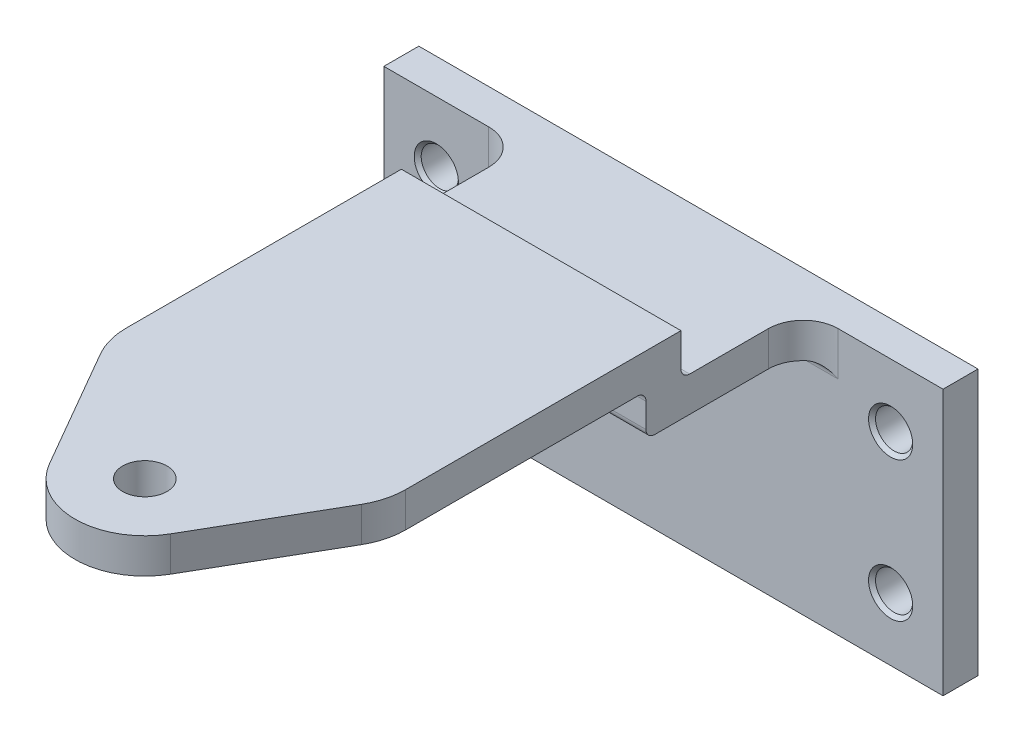
from build123d import *

# Parameters (mm, degrees)
SKETCH1_R                        = 4.03225
BOSS_EXTRUDE1_DEPTH              = 3.175
FILLET1_R                        = 12.7
EXTRUDE_THIN1_DEPTH              = 50.8
SKETCH3_W                        = 6.35
SKETCH3_H                        = 48.26
BOSS_EXTRUDE2_DEPTH              = 25.4
F_1_4_CLEARANCE_HOLE1_AT_2_COUNT = 2
F_1_4_CLEARANCE_HOLE1_AT_2_PITCH = 25.4
FILLET2_R                        = 6.35
FILLET3_R                        = 1.5875


with BuildPart() as part:
    # Sketch1 → Boss-Extrude1 (new, symmetric)
    with BuildSketch(Plane(origin=(0, 0, 0), x_dir=(1, 0, 0), z_dir=(0, 1, 0))):
        with BuildLine():
            Line((-25.4, 50.8), (25.4, 50.8))
            Line((25.4, 50.8), (25.4, 18.594090512))
            Line((25.4, 18.594090512), (10.998522628, -6.35))
            ThreePointArc((10.998522628, -6.35), (0, -12.7), (-10.998522628, -6.35))
            Line((-10.998522628, -6.35), (-25.4, 18.594090512))
            Line((-25.4, 18.594090512), (-25.4, 50.8))
        make_face()
        with Locations(Location((0, 0, 0), (0, 0, 270))):
            Circle(SKETCH1_R, mode=Mode.SUBTRACT)
    extrude(amount=BOSS_EXTRUDE1_DEPTH, both=True)

    # Fillet1
    fillet1_edges = [part.edges().sort_by_distance(p)[0] for p in [
        (25.4, 0, -18.594090512),
        (-25.4, 0, -18.594090512),
    ]]
    fillet(fillet1_edges, radius=FILLET1_R)

    # Sketch2 → Extrude-Thin1 (add)
    with BuildSketch(Plane(origin=(25.4, 0, 0), x_dir=(0, 0, -1), z_dir=(1, 0, 0))):
        Polygon((50.8, 3.175), (72.009, 3.175), (72.009, -4.445), (100.584, -4.445), (100.584, -52.705), (94.234, -52.705), (94.234, -10.795), (65.659, -10.795), (65.659, -3.175), (50.8, -3.175), align=None)
    extrude(amount=-EXTRUDE_THIN1_DEPTH)

    # Sketch3 → Boss-Extrude2 (add)
    with BuildSketch(Plane(origin=(25.4, 0, 0), x_dir=(0, 0, -1), z_dir=(1, 0, 0))):
        with Locations((97.409, -28.575)):
            Rectangle(SKETCH3_W, SKETCH3_H)
    boss_extrude2 = extrude(amount=BOSS_EXTRUDE2_DEPTH)

    # Sketch5 → 1/4 Clearance Hole1 (revolve, cut)
    with BuildSketch(Plane(origin=(41.275, -15.875, -94.234), x_dir=(0, -1, 0), z_dir=(1, 0, 0))):
        Polygon((0, 0), (0, 6.35), (4.0132, 6.35), (3.3782, 5.715), (3.3782, 0.635), (4.0132, 0), align=None)
    f_1_4_clearance_hole1 = revolve(axis=Axis((41.275, -15.875, -87.884), (0, 0, -1)), mode=Mode.SUBTRACT)

    # 1/4 Clearance Hole1 at 2: 1/4 Clearance Hole1 ×2
    with Locations(*[(0, -i * F_1_4_CLEARANCE_HOLE1_AT_2_PITCH, 0) for i in range(1, F_1_4_CLEARANCE_HOLE1_AT_2_COUNT)]):
        add(f_1_4_clearance_hole1, mode=Mode.SUBTRACT)

    # Mirror1: Boss-Extrude2, 1/4 Clearance Hole1 across plane
    add(boss_extrude2.mirror(Plane(origin=(0, 0, 0), x_dir=(0, 0, 1), z_dir=(1, 0, 0))))
    add(f_1_4_clearance_hole1.mirror(Plane(origin=(0, 0, 0), x_dir=(0, 0, 1), z_dir=(1, 0, 0))), mode=Mode.SUBTRACT)

    # Mirror1 copy 1 sketch → Mirror1 copy 1 (revolve, cut)
    with BuildSketch(Plane(origin=(-41.275, -41.275, -94.234), x_dir=(0, -1, 0), z_dir=(-1, 0, 0))):
        Polygon((0, 0), (0, -6.35), (4.0132, -6.35), (3.3782, -5.715), (3.3782, -0.635), (4.0132, 0), align=None)
    revolve(axis=Axis((-41.275, -41.275, -87.884), (0, 0, 1)), mode=Mode.SUBTRACT)

    # Fillet2
    fillet2_edges = [part.edges().sort_by_distance(p)[0] for p in [
        (25.4, -7.62, -94.234),
        (-25.4, -7.62, -94.234),
    ]]
    fillet(fillet2_edges, radius=FILLET2_R)

    # Fillet3
    fillet3_edges = [part.edges().sort_by_distance(p)[0] for p in [
        (0, -4.445, -72.009),
        (0, -3.175, -65.659),
        (0, -10.795, -65.659),
        (0, -10.795, -94.234),
    ]]
    fillet(fillet3_edges, radius=FILLET3_R)


solid = part.part
